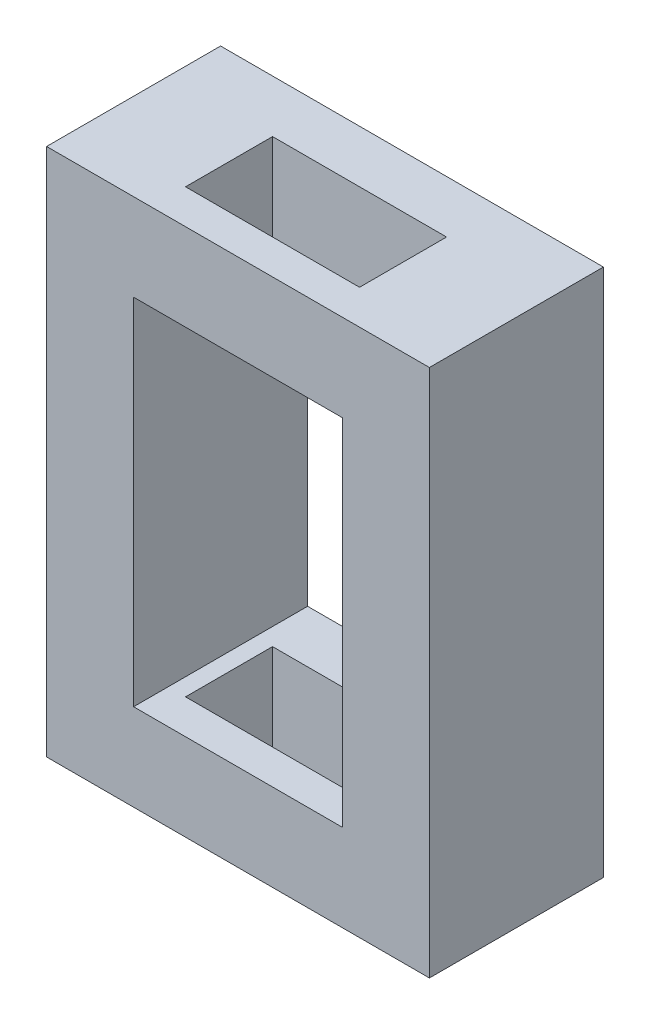
from build123d import *

# Parameters (mm, degrees)
SKETCH2_W           = 11
SKETCH2_H           = 15.192307692
SKETCH2_W_2         = 6
SKETCH2_H_2         = 10.192307692
BOSS_EXTRUDE1_DEPTH = 5
SKETCH3_W           = 5
SKETCH3_H           = 2.5
CUT_EXTRUDE1_DEPTH  = 16


with BuildPart() as part:
    # Sketch2 → Boss-Extrude1 (new body)
    with BuildSketch(Plane.XY):
        with Locations((-5.497265609, 2.901684774)):
            Rectangle(SKETCH2_W, SKETCH2_H)
        with Locations((-5.497265609, 2.901684774)):
            Rectangle(SKETCH2_W_2, SKETCH2_H_2, mode=Mode.SUBTRACT)
    extrude(amount=BOSS_EXTRUDE1_DEPTH)

    # Sketch3 → Cut-Extrude1 (cut)
    with BuildSketch(Plane(origin=(0, 10.49783862, 0), x_dir=(1, 0, 0), z_dir=(0, 1, 0))):
        with Locations((-5.497265609, -2.757136722)):
            Rectangle(SKETCH3_W, SKETCH3_H)
    extrude(amount=-CUT_EXTRUDE1_DEPTH, mode=Mode.SUBTRACT)


solid = part.part
